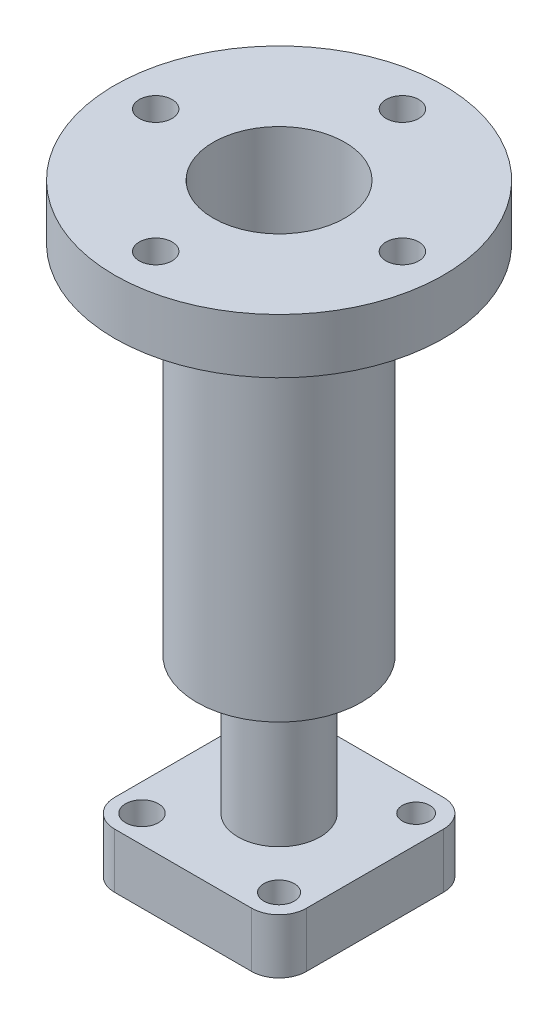
from build123d import *

# Parameters (mm, degrees)
SKETCH2_R                      = 6
CUT_EXTRUDE1_DEPTH             = 201
CIRPATTERN1_COUNT              = 4
SKETCH3_R                      = 24
CUT_EXTRUDE2_DEPTH             = 144
BOSS_EXTRUDE2_DEPTH            = 20
CUT_EXTRUDE3_REACH             = 222
SKETCH8_R                      = 6
CUT_EXTRUDE4_REACH             = 222
SKETCH10_R                     = 5.551973051
CUT_EXTRUDE5_REACH             = 222
SKETCH11_R                     = 5
CUT_EXTRUDE6_REACH             = 222
SKETCH12_R                     = 5
CUT_EXTRUDE6_DIRECTION_2_DEPTH = 1


with BuildPart() as part:
    # Sketch1 → Revolve1 (revolve)
    with BuildSketch(Plane.XY):
        Polygon((0, 0), (15, 0), (15, 50), (30, 50), (30, 180), (60, 180), (60, 200), (0, 200), align=None)
    revolve(axis=Axis((0, 218.08318264, 0), (0, -1, 0)))

    # Sketch2 → Cut-Extrude1 (cut, through all)
    with BuildSketch(Plane(origin=(0, 200, 0), x_dir=(1, 0, 0), z_dir=(0, 1, 0))):
        with Locations((0, 45)):
            Circle(SKETCH2_R)
    cut_extrude1 = extrude(amount=-CUT_EXTRUDE1_DEPTH, mode=Mode.SUBTRACT)

    # CirPattern1: Cut-Extrude1 ×4 about axis
    cirpattern1_axis = Axis((0, 0, 0), (0, 1, 0))
    for i in range(1, CIRPATTERN1_COUNT):
        add(cut_extrude1.rotate(cirpattern1_axis, i * 360 / CIRPATTERN1_COUNT), mode=Mode.SUBTRACT)

    # Sketch3 → Cut-Extrude2 (cut)
    with BuildSketch(Plane(origin=(0, 200, 0), x_dir=(1, 0, 0), z_dir=(0, 1, 0))):
        Circle(SKETCH3_R)
    extrude(amount=-CUT_EXTRUDE2_DEPTH, mode=Mode.SUBTRACT)

    # Sketch4 → Boss-Extrude2 (add)
    with BuildSketch(Plane.XZ):
        with BuildLine():
            Line((-25, 35), (25, 35))
            ThreePointArc((25, 35), (32.071067812, 32.071067812), (35, 25))
            Line((35, 25), (35, -25))
            ThreePointArc((35, -25), (32.071067812, -32.071067812), (25, -35))
            Line((25, -35), (-25, -35))
            ThreePointArc((-25, -35), (-32.071067812, -32.071067812), (-35, -25))
            Line((-35, -25), (-35, 25))
            ThreePointArc((-35, 25), (-32.071067812, 32.071067812), (-25, 35))
        make_face()
    extrude(amount=BOSS_EXTRUDE2_DEPTH)

    # Sketch8 → Cut-Extrude3 (cut, up to next)
    with BuildSketch(Plane.XZ.offset(20), mode=Mode.PRIVATE) as cut_extrude3_sk1:
        with Locations((-25, 25)):
            Circle(SKETCH8_R)
    cut_extrude3_tool1 = extrude(cut_extrude3_sk1.sketch, amount=-CUT_EXTRUDE3_REACH, mode=Mode.PRIVATE) & part.part
    add(cut_extrude3_tool1.solids().sort_by_distance((-25, -20, 25))[0], mode=Mode.SUBTRACT)

    # Sketch10 → Cut-Extrude4 (cut, up to next)
    with BuildSketch(Plane(origin=(0, -20, 0), x_dir=(-1, 0, 0), z_dir=(0, -1, 0)), mode=Mode.PRIVATE) as cut_extrude4_sk1:
        with Locations((-25, -25)):
            Circle(SKETCH10_R)
    cut_extrude4_tool1 = extrude(cut_extrude4_sk1.sketch, amount=-CUT_EXTRUDE4_REACH, mode=Mode.PRIVATE) & part.part
    add(cut_extrude4_tool1.solids().sort_by_distance((25, -20, 25))[0], mode=Mode.SUBTRACT)

    # Sketch11 → Cut-Extrude5 (cut, up to next)
    with BuildSketch(Plane(origin=(0, -20, 0), x_dir=(-1, 0, 0), z_dir=(0, -1, 0)), mode=Mode.PRIVATE) as cut_extrude5_sk1:
        with Locations((-25, 25)):
            Circle(SKETCH11_R)
    cut_extrude5_tool1 = extrude(cut_extrude5_sk1.sketch, amount=-CUT_EXTRUDE5_REACH, mode=Mode.PRIVATE) & part.part
    add(cut_extrude5_tool1.solids().sort_by_distance((25, -20, -25))[0], mode=Mode.SUBTRACT)

    # Sketch12 → Cut-Extrude6 (cut, up to next)
    with BuildSketch(Plane.XZ.offset(20), mode=Mode.PRIVATE) as cut_extrude6_sk1:
        with Locations((-25, -25)):
            Circle(SKETCH12_R)
    cut_extrude6_tool1 = extrude(cut_extrude6_sk1.sketch, amount=-CUT_EXTRUDE6_REACH, mode=Mode.PRIVATE) & part.part
    add(cut_extrude6_tool1.solids().sort_by_distance((-25, -20, -25))[0], mode=Mode.SUBTRACT)

    # Sketch12 → Cut-Extrude6 direction 2 (cut)
    with BuildSketch(Plane.XZ.offset(20)):
        with Locations((-25, -25)):
            Circle(SKETCH12_R)
    extrude(amount=CUT_EXTRUDE6_DIRECTION_2_DEPTH, mode=Mode.SUBTRACT)


solid = part.part
